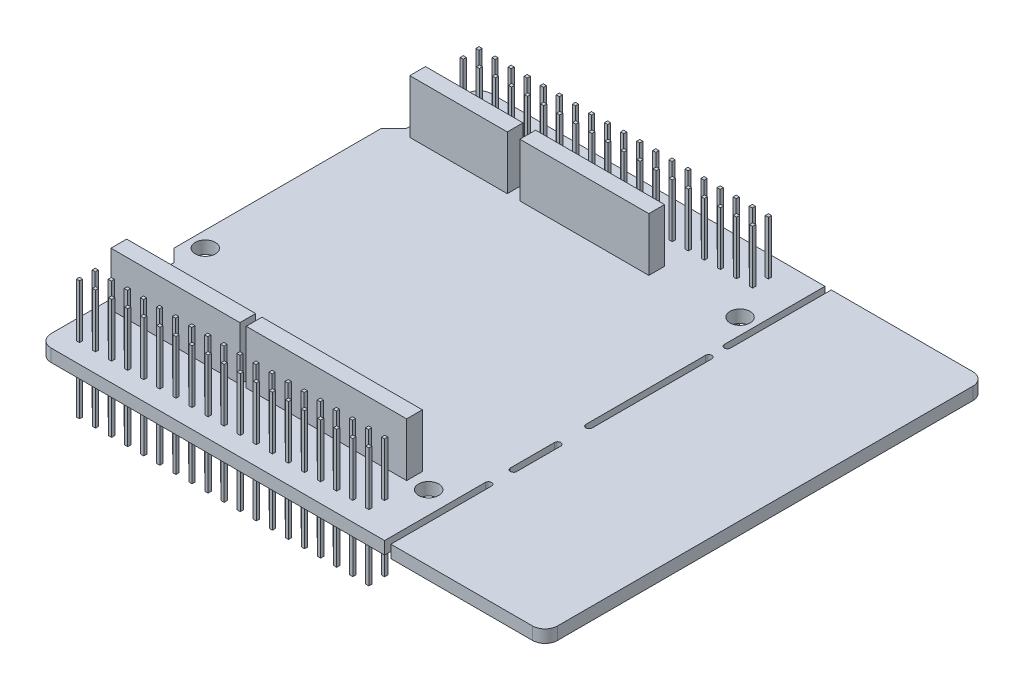
from build123d import *

# Parameters (mm, degrees)
SZKIC2_R                         = 1.6
DODANIE_WYCI_GNI_CIE1_DEPTH      = 2
SZKIC3_W                         = 15.5
SZKIC3_H                         = 2.5
SZKIC3_W_2                       = 20.5
SZKIC3_W_3                       = 25.5
DODANIE_WYCI_GNI_CIE2_DEPTH      = 8.5
SZKIC4_W                         = 0.5
SZKIC4_H                         = 0.5
DODANIE_WYCI_GNI_CIE3_DEPTH      = 8.5
DODANIE_WYCI_GNI_CIE3_DEPTH_BACK = 10.5


with BuildPart() as part:
    # Szkic2 → Dodanie-wyciągnięcie1 (new body)
    with BuildSketch(Plane(origin=(0, 0, 0), x_dir=(1, 0, 0), z_dir=(0, 1, 0))):
        with BuildLine():
            Line((-43.319305218, 25.801941522), (-43.319305218, -7.198058478))
            Line((-43.319305218, -7.198058478), (-41.319305218, -9.198058478))
            Line((-41.319305218, -9.198058478), (-41.319305218, -28.698058478))
            ThreePointArc((-41.319305218, -28.698058478), (-40.73351878, -30.11227204), (-39.319305218, -30.698058478))
            Line((-39.319305218, -30.698058478), (13.680694782, -30.698058478))
            Line((13.680694782, -30.698058478), (13.680694782, -14.698058478))
            ThreePointArc((13.680694782, -14.698058478), (14.180694782, -14.198058478), (14.680694782, -14.698058478))
            Line((14.680694782, -14.698058478), (14.680694782, -30.698058478))
            Line((14.680694782, -30.698058478), (37.180694782, -30.698058478))
            ThreePointArc((37.180694782, -30.698058478), (38.594908344, -30.11227204), (39.180694782, -28.698058478))
            Line((39.180694782, -28.698058478), (39.180694782, 37.301941522))
            ThreePointArc((39.180694782, 37.301941522), (38.594908344, 38.716155084), (37.180694782, 39.301941522))
            Line((37.180694782, 39.301941522), (14.680694782, 39.301941522))
            Line((14.680694782, 39.301941522), (14.680694782, 23.301941522))
            ThreePointArc((14.680694782, 23.301941522), (14.180694782, 22.801941522), (13.680694782, 23.301941522))
            Line((13.680694782, 23.301941522), (13.680694782, 39.301941522))
            Line((13.680694782, 39.301941522), (-39.319305218, 39.301941522))
            ThreePointArc((-39.319305218, 39.301941522), (-40.73351878, 38.716155084), (-41.319305218, 37.301941522))
            Line((-41.319305218, 37.301941522), (-41.319305218, 27.801941522))
            Line((-41.319305218, 27.801941522), (-43.319305218, 25.801941522))
        make_face()
        with Locations((-40.819305218, -4.698058478)):
            Circle(SZKIC2_R, mode=Mode.SUBTRACT)
        with Locations((10.180694782, -20.198058478)):
            Circle(SZKIC2_R, mode=Mode.SUBTRACT)
        with BuildLine():
            ThreePointArc((13.680694782, -3.698058478), (14.180694782, -3.198058478), (14.680694782, -3.698058478))
            Line((14.680694782, -3.698058478), (14.680694782, -10.698058478))
            ThreePointArc((14.680694782, -10.698058478), (14.180694782, -11.198058478), (13.680694782, -10.698058478))
            Line((13.680694782, -10.698058478), (13.680694782, -3.698058478))
        make_face(mode=Mode.SUBTRACT)
        with BuildLine():
            ThreePointArc((13.680694782, 20.301941522), (14.180694782, 20.801941522), (14.680694782, 20.301941522))
            Line((14.680694782, 20.301941522), (14.680694782, 1.301941522))
            ThreePointArc((14.680694782, 1.301941522), (14.180694782, 0.801941522), (13.680694782, 1.301941522))
            Line((13.680694782, 1.301941522), (13.680694782, 20.301941522))
        make_face(mode=Mode.SUBTRACT)
        with Locations((11.180694782, 28.301941522)):
            Circle(SZKIC2_R, mode=Mode.SUBTRACT)
    extrude(amount=DODANIE_WYCI_GNI_CIE1_DEPTH)

    # Szkic3 → Dodanie-wyciągnięcie2 (add)
    with BuildSketch(Plane(origin=(0, 2, 0), x_dir=(1, 0, 0), z_dir=(0, 1, 0))):
        with Locations((-32.069305218, 28.051941522)):
            Rectangle(SZKIC3_W, SZKIC3_H)
        with Locations((-12.069305218, 28.051941522)):
            Rectangle(SZKIC3_W_2, SZKIC3_H)
        with Locations((-29.569305218, -19.448058478)):
            Rectangle(SZKIC3_W_2, SZKIC3_H)
        with Locations((-5.569305218, -19.448058478)):
            Rectangle(SZKIC3_W_3, SZKIC3_H)
    extrude(amount=DODANIE_WYCI_GNI_CIE2_DEPTH)

    # Szkic4 → Dodanie-wyciągnięcie3 (add, two sides)
    with BuildSketch(Plane(origin=(0, 0, 0), x_dir=(-1, 0, 0), z_dir=(0, -1, 0))) as dodanie_wyci_gni_cie3_sk:
        with Locations((-7.930694782, 36.051941522)):
            Rectangle(SZKIC4_W, SZKIC4_H)
        with Locations((-7.930694782, 33.551941522)):
            Rectangle(SZKIC4_W, SZKIC4_H)
        with Locations((-5.375139226, 36.051941522)):
            Rectangle(SZKIC4_W, SZKIC4_H)
        with Locations((-5.375139226, 33.551941522)):
            Rectangle(SZKIC4_W, SZKIC4_H)
        with Locations((-2.819583671, 36.051941522)):
            Rectangle(SZKIC4_W, SZKIC4_H)
        with Locations((-2.819583671, 33.551941522)):
            Rectangle(SZKIC4_W, SZKIC4_H)
        with Locations((-0.264028115, 36.051941522)):
            Rectangle(SZKIC4_W, SZKIC4_H)
        with Locations((-0.264028115, 33.551941522)):
            Rectangle(SZKIC4_W, SZKIC4_H)
        with Locations((2.29152744, 36.051941522)):
            Rectangle(SZKIC4_W, SZKIC4_H)
        with Locations((2.29152744, 33.551941522)):
            Rectangle(SZKIC4_W, SZKIC4_H)
        with Locations((4.847082996, 36.051941522)):
            Rectangle(SZKIC4_W, SZKIC4_H)
        with Locations((4.847082996, 33.551941522)):
            Rectangle(SZKIC4_W, SZKIC4_H)
        with Locations((7.402638551, 36.051941522)):
            Rectangle(SZKIC4_W, SZKIC4_H)
        with Locations((7.402638551, 33.551941522)):
            Rectangle(SZKIC4_W, SZKIC4_H)
        with Locations((9.958194107, 36.051941522)):
            Rectangle(SZKIC4_W, SZKIC4_H)
        with Locations((9.958194107, 33.551941522)):
            Rectangle(SZKIC4_W, SZKIC4_H)
        with Locations((12.513749663, 36.051941522)):
            Rectangle(SZKIC4_W, SZKIC4_H)
        with Locations((12.513749663, 33.551941522)):
            Rectangle(SZKIC4_W, SZKIC4_H)
        with Locations((15.069305218, 36.051941522)):
            Rectangle(SZKIC4_W, SZKIC4_H)
        with Locations((15.069305218, 33.551941522)):
            Rectangle(SZKIC4_W, SZKIC4_H)
        with Locations((17.624860774, 36.051941522)):
            Rectangle(SZKIC4_W, SZKIC4_H)
        with Locations((17.624860774, 33.551941522)):
            Rectangle(SZKIC4_W, SZKIC4_H)
        with Locations((20.180416329, 36.051941522)):
            Rectangle(SZKIC4_W, SZKIC4_H)
        with Locations((20.180416329, 33.551941522)):
            Rectangle(SZKIC4_W, SZKIC4_H)
        with Locations((22.735971885, 36.051941522)):
            Rectangle(SZKIC4_W, SZKIC4_H)
        with Locations((22.735971885, 33.551941522)):
            Rectangle(SZKIC4_W, SZKIC4_H)
        with Locations((25.29152744, 36.051941522)):
            Rectangle(SZKIC4_W, SZKIC4_H)
        with Locations((25.29152744, 33.551941522)):
            Rectangle(SZKIC4_W, SZKIC4_H)
        with Locations((27.847082996, 36.051941522)):
            Rectangle(SZKIC4_W, SZKIC4_H)
        with Locations((27.847082996, 33.551941522)):
            Rectangle(SZKIC4_W, SZKIC4_H)
        with Locations((30.402638551, 36.051941522)):
            Rectangle(SZKIC4_W, SZKIC4_H)
        with Locations((30.402638551, 33.551941522)):
            Rectangle(SZKIC4_W, SZKIC4_H)
        with Locations((32.958194107, 36.051941522)):
            Rectangle(SZKIC4_W, SZKIC4_H)
        with Locations((32.958194107, 33.551941522)):
            Rectangle(SZKIC4_W, SZKIC4_H)
        with Locations((35.513749663, 36.051941522)):
            Rectangle(SZKIC4_W, SZKIC4_H)
        with Locations((35.513749663, 33.551941522)):
            Rectangle(SZKIC4_W, SZKIC4_H)
        with Locations((38.069305218, 36.051941522)):
            Rectangle(SZKIC4_W, SZKIC4_H)
        with Locations((38.069305218, 33.551941522)):
            Rectangle(SZKIC4_W, SZKIC4_H)
        with Locations((-7.930694782, -24.948058478)):
            Rectangle(SZKIC4_W, SZKIC4_H)
        with Locations((-7.930694782, -27.448058478)):
            Rectangle(SZKIC4_W, SZKIC4_H)
        with Locations((-5.375139226, -24.948058478)):
            Rectangle(SZKIC4_W, SZKIC4_H)
        with Locations((-5.375139226, -27.448058478)):
            Rectangle(SZKIC4_W, SZKIC4_H)
        with Locations((-2.819583671, -24.948058478)):
            Rectangle(SZKIC4_W, SZKIC4_H)
        with Locations((-2.819583671, -27.448058478)):
            Rectangle(SZKIC4_W, SZKIC4_H)
        with Locations((-0.264028115, -24.948058478)):
            Rectangle(SZKIC4_W, SZKIC4_H)
        with Locations((-0.264028115, -27.448058478)):
            Rectangle(SZKIC4_W, SZKIC4_H)
        with Locations((2.29152744, -24.948058478)):
            Rectangle(SZKIC4_W, SZKIC4_H)
        with Locations((2.29152744, -27.448058478)):
            Rectangle(SZKIC4_W, SZKIC4_H)
        with Locations((4.847082996, -24.948058478)):
            Rectangle(SZKIC4_W, SZKIC4_H)
        with Locations((4.847082996, -27.448058478)):
            Rectangle(SZKIC4_W, SZKIC4_H)
        with Locations((7.402638551, -24.948058478)):
            Rectangle(SZKIC4_W, SZKIC4_H)
        with Locations((7.402638551, -27.448058478)):
            Rectangle(SZKIC4_W, SZKIC4_H)
        with Locations((9.958194107, -24.948058478)):
            Rectangle(SZKIC4_W, SZKIC4_H)
        with Locations((9.958194107, -27.448058478)):
            Rectangle(SZKIC4_W, SZKIC4_H)
        with Locations((12.513749663, -24.948058478)):
            Rectangle(SZKIC4_W, SZKIC4_H)
        with Locations((12.513749663, -27.448058478)):
            Rectangle(SZKIC4_W, SZKIC4_H)
        with Locations((15.069305218, -24.948058478)):
            Rectangle(SZKIC4_W, SZKIC4_H)
        with Locations((15.069305218, -27.448058478)):
            Rectangle(SZKIC4_W, SZKIC4_H)
        with Locations((17.624860774, -24.948058478)):
            Rectangle(SZKIC4_W, SZKIC4_H)
        with Locations((17.624860774, -27.448058478)):
            Rectangle(SZKIC4_W, SZKIC4_H)
        with Locations((20.180416329, -24.948058478)):
            Rectangle(SZKIC4_W, SZKIC4_H)
        with Locations((20.180416329, -27.448058478)):
            Rectangle(SZKIC4_W, SZKIC4_H)
        with Locations((22.735971885, -24.948058478)):
            Rectangle(SZKIC4_W, SZKIC4_H)
        with Locations((22.735971885, -27.448058478)):
            Rectangle(SZKIC4_W, SZKIC4_H)
        with Locations((25.29152744, -24.948058478)):
            Rectangle(SZKIC4_W, SZKIC4_H)
        with Locations((25.29152744, -27.448058478)):
            Rectangle(SZKIC4_W, SZKIC4_H)
        with Locations((27.847082996, -24.948058478)):
            Rectangle(SZKIC4_W, SZKIC4_H)
        with Locations((27.847082996, -27.448058478)):
            Rectangle(SZKIC4_W, SZKIC4_H)
        with Locations((30.402638551, -24.948058478)):
            Rectangle(SZKIC4_W, SZKIC4_H)
        with Locations((30.402638551, -27.448058478)):
            Rectangle(SZKIC4_W, SZKIC4_H)
        with Locations((32.958194107, -24.948058478)):
            Rectangle(SZKIC4_W, SZKIC4_H)
        with Locations((32.958194107, -27.448058478)):
            Rectangle(SZKIC4_W, SZKIC4_H)
        with Locations((35.513749663, -24.948058478)):
            Rectangle(SZKIC4_W, SZKIC4_H)
        with Locations((35.513749663, -27.448058478)):
            Rectangle(SZKIC4_W, SZKIC4_H)
        with Locations((38.069305218, -24.948058478)):
            Rectangle(SZKIC4_W, SZKIC4_H)
        with Locations((38.069305218, -27.448058478)):
            Rectangle(SZKIC4_W, SZKIC4_H)
    extrude(amount=DODANIE_WYCI_GNI_CIE3_DEPTH)
    extrude(dodanie_wyci_gni_cie3_sk.sketch, amount=-DODANIE_WYCI_GNI_CIE3_DEPTH_BACK)


solid = part.part
